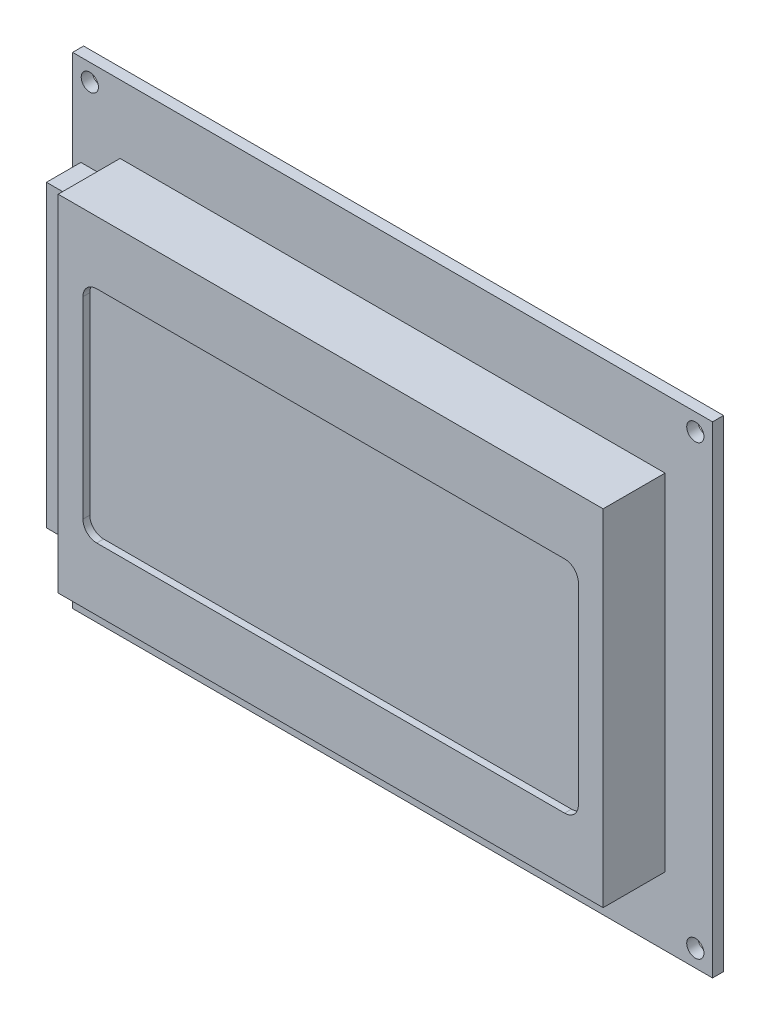
from build123d import *

# Parameters (mm, degrees)
BOSS_EXTRUDE1_DEPTH = 8
SKETCH1_W           = 79.2
SKETCH1_H           = 50.2
BOSS_EXTRUDE2_DEPTH = 9
SKETCH2_W           = 93
SKETCH2_H           = 70
SKETCH2_R           = 1.25
SKETCH2_R_2         = 0.5
BOSS_EXTRUDE3_DEPTH = 1.6
SKETCH3_W           = 5.7
SKETCH3_H           = 43.5
BOSS_EXTRUDE4_DEPTH = 5


with BuildPart() as part:
    # Esboço1 → Boss-Extrude1 (new body)
    with BuildSketch(Plane.XY):
        with BuildLine():
            ThreePointArc((-34, -16), (-35.414213562, -15.414213562), (-36, -14))
            Line((-36, -14), (-36, 14))
            ThreePointArc((-36, 14), (-35.414213562, 15.414213562), (-34, 16))
            Line((-34, 16), (34, 16))
            ThreePointArc((34, 16), (35.414213562, 15.414213562), (36, 14))
            Line((36, 14), (36, -14))
            ThreePointArc((36, -14), (35.414213562, -15.414213562), (34, -16))
            Line((34, -16), (-34, -16))
        make_face()
    extrude(amount=BOSS_EXTRUDE1_DEPTH)

    # Sketch1 → Boss-Extrude2 (add)
    with BuildSketch(Plane.XY):
        Rectangle(SKETCH1_W, SKETCH1_H)
        with BuildLine():
            Line((-34, -16), (34, -16))
            ThreePointArc((34, -16), (35.414213562, -15.414213562), (36, -14))
            Line((36, -14), (36, 14))
            ThreePointArc((36, 14), (35.414213562, 15.414213562), (34, 16))
            Line((34, 16), (-34, 16))
            ThreePointArc((-34, 16), (-35.414213562, 15.414213562), (-36, 14))
            Line((-36, 14), (-36, -14))
            ThreePointArc((-36, -14), (-35.414213562, -15.414213562), (-34, -16))
        make_face(mode=Mode.SUBTRACT)
    extrude(amount=BOSS_EXTRUDE2_DEPTH)

    # Sketch3 → Boss-Extrude4 (add)
    with BuildSketch(Plane.XY):
        with Locations((-42.45, 0)):
            Rectangle(SKETCH3_W, SKETCH3_H)
    extrude(amount=BOSS_EXTRUDE4_DEPTH)


with BuildPart() as body_2:
    # Sketch2 → Boss-Extrude3 (new body)
    with BuildSketch(Plane.XY):
        Rectangle(SKETCH2_W, SKETCH2_H)
        with Locations((-44, 32.5)):
            Circle(SKETCH2_R, mode=Mode.SUBTRACT)
        with Locations((44, 32.5)):
            Circle(SKETCH2_R, mode=Mode.SUBTRACT)
        with Locations((44, -32.5)):
            Circle(SKETCH2_R, mode=Mode.SUBTRACT)
        with Locations((-44, -32.5)):
            Circle(SKETCH2_R, mode=Mode.SUBTRACT)
        with Locations((-35, -33)):
            Circle(SKETCH2_R_2, mode=Mode.SUBTRACT)
        with Locations((13.26, -33)):
            Circle(SKETCH2_R_2, mode=Mode.SUBTRACT)
        with Locations((-32.46, -33)):
            Circle(SKETCH2_R_2, mode=Mode.SUBTRACT)
        with Locations((-29.92, -33)):
            Circle(SKETCH2_R_2, mode=Mode.SUBTRACT)
        with Locations((-27.38, -33)):
            Circle(SKETCH2_R_2, mode=Mode.SUBTRACT)
        with Locations((-24.84, -33)):
            Circle(SKETCH2_R_2, mode=Mode.SUBTRACT)
        with Locations((-22.3, -33)):
            Circle(SKETCH2_R_2, mode=Mode.SUBTRACT)
        with Locations((-19.76, -33)):
            Circle(SKETCH2_R_2, mode=Mode.SUBTRACT)
        with Locations((-17.22, -33)):
            Circle(SKETCH2_R_2, mode=Mode.SUBTRACT)
        with Locations((-14.68, -33)):
            Circle(SKETCH2_R_2, mode=Mode.SUBTRACT)
        with Locations((-12.14, -33)):
            Circle(SKETCH2_R_2, mode=Mode.SUBTRACT)
        with Locations((-9.6, -33)):
            Circle(SKETCH2_R_2, mode=Mode.SUBTRACT)
        with Locations((-7.06, -33)):
            Circle(SKETCH2_R_2, mode=Mode.SUBTRACT)
        with Locations((-4.52, -33)):
            Circle(SKETCH2_R_2, mode=Mode.SUBTRACT)
        with Locations((-1.98, -33)):
            Circle(SKETCH2_R_2, mode=Mode.SUBTRACT)
        with Locations((0.56, -33)):
            Circle(SKETCH2_R_2, mode=Mode.SUBTRACT)
        with Locations((3.1, -33)):
            Circle(SKETCH2_R_2, mode=Mode.SUBTRACT)
        with Locations((5.64, -33)):
            Circle(SKETCH2_R_2, mode=Mode.SUBTRACT)
        with Locations((8.18, -33)):
            Circle(SKETCH2_R_2, mode=Mode.SUBTRACT)
        with Locations((10.72, -33)):
            Circle(SKETCH2_R_2, mode=Mode.SUBTRACT)
    extrude(amount=-BOSS_EXTRUDE3_DEPTH)


solid = Compound([part.part, body_2.part])
